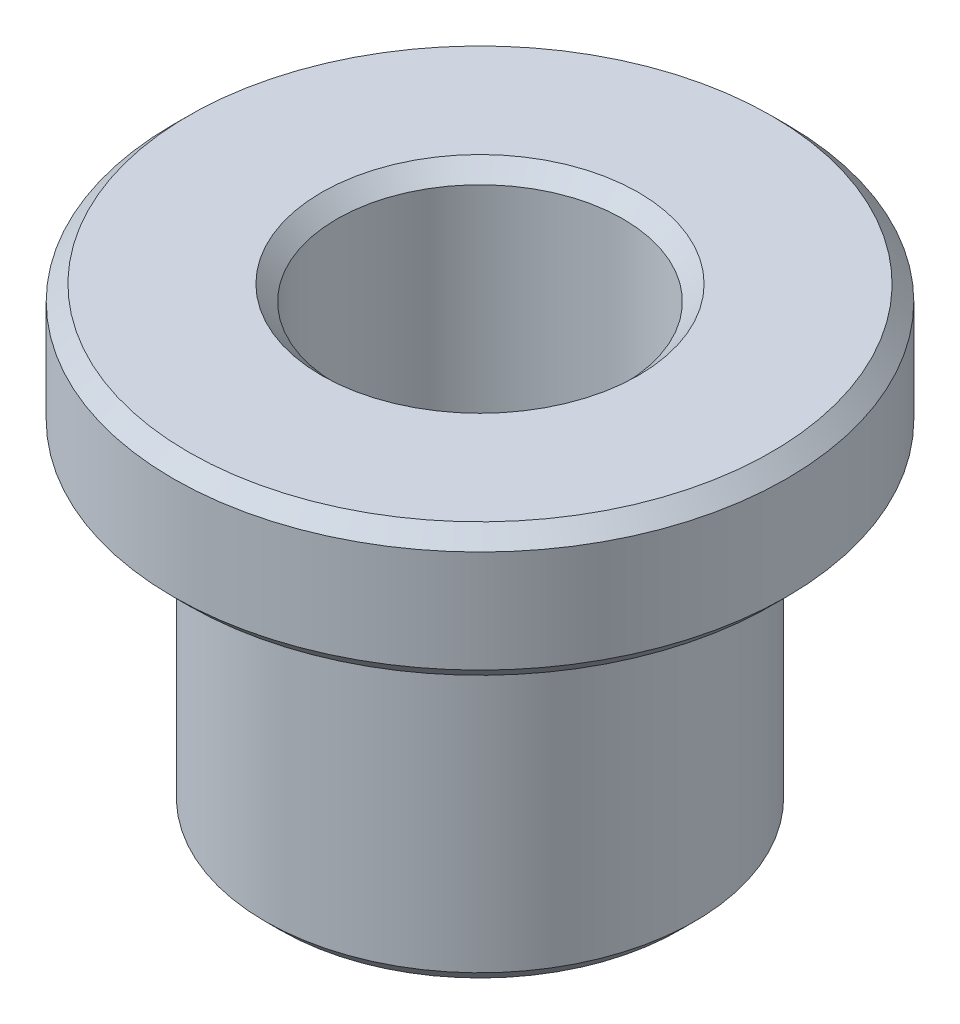
from build123d import *

# Parameters (mm, degrees)
SKETCH_1_R          = 21
EXTRUDE_1_DEPTH     = 32
SKETCH_2_R          = 30
EXTRUDE_2_DEPTH     = 13
SKETCH_3_R          = 14
CUT_EXTRUDE_1_DEPTH = 46
CHAMFER_1_SIZE      = 1.5


with BuildPart() as part:
    # 草图1 → 凸台-拉伸1 (new body)
    with BuildSketch(Plane(origin=(0, 0, 0), x_dir=(1, 0, 0), z_dir=(0, 1, 0))):
        Circle(SKETCH_1_R)
    extrude(amount=EXTRUDE_1_DEPTH)

    # 草图2 → 凸台-拉伸2 (add)
    with BuildSketch(Plane(origin=(0, 32, 0), x_dir=(1, 0, 0), z_dir=(0, 1, 0))):
        Circle(SKETCH_2_R)
    extrude(amount=EXTRUDE_2_DEPTH)

    # 草图3 → 切除-拉伸1 (cut, through all)
    with BuildSketch(Plane(origin=(0, 45, 0), x_dir=(1, 0, 0), z_dir=(0, 1, 0))):
        Circle(SKETCH_3_R)
    extrude(amount=-CUT_EXTRUDE_1_DEPTH, mode=Mode.SUBTRACT)

    # 倒角1
    chamfer_1_edges = [part.edges().sort_by_distance(p)[0] for p in [
        (-14, 0, 0),
        (-14, 45, 0),
        (-21, 0, 0),
        (-30, 32, 0),
        (-30, 45, 0),
    ]]
    chamfer(chamfer_1_edges, length=CHAMFER_1_SIZE)


solid = part.part
